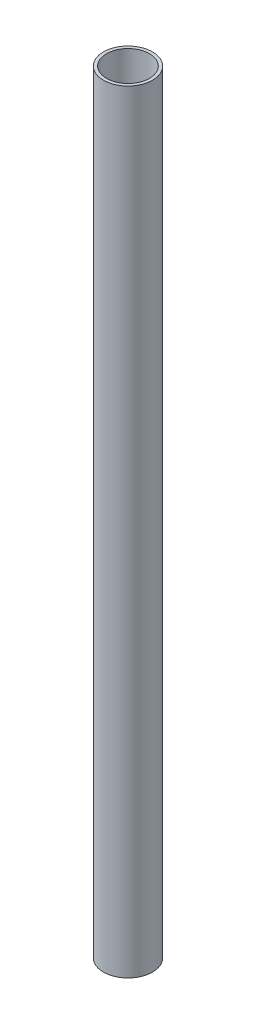
from build123d import *

# Parameters (mm, degrees)
SKETCH1_R           = 12.7
SKETCH1_R_2         = 11.1125
BOSS_EXTRUDE1_DEPTH = 400


with BuildPart() as part:
    # Sketch1 → Boss-Extrude1 (new body)
    with BuildSketch(Plane(origin=(0, 0, 0), x_dir=(1, 0, 0), z_dir=(0, 1, 0))):
        Circle(SKETCH1_R)
        Circle(SKETCH1_R_2, mode=Mode.SUBTRACT)
    extrude(amount=BOSS_EXTRUDE1_DEPTH)


solid = part.part
